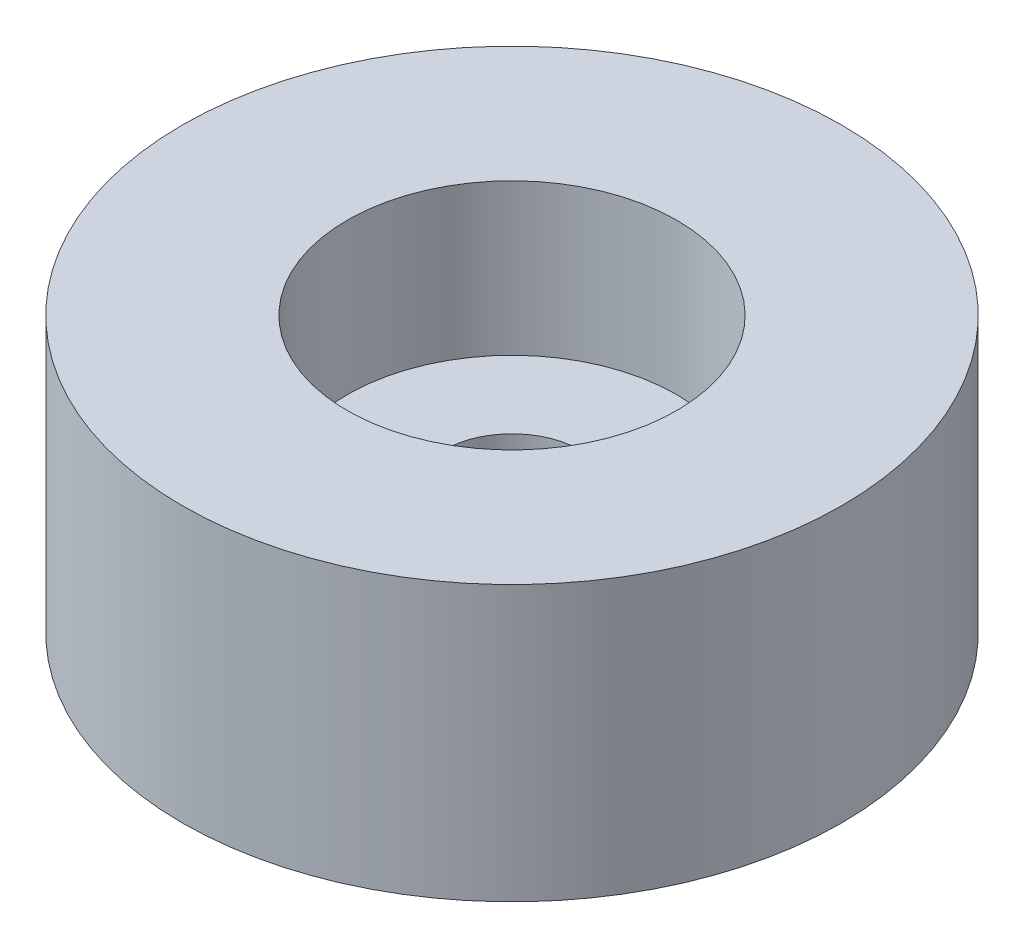
from build123d import *

# Parameters (mm, degrees)
SKETCH1_4_W = 5.55625
SKETCH1_4_H = 2


with BuildPart() as part:
    # Sketch1 → Revolve1 (revolve)
    with BuildSketch(Plane.XY):
        Polygon((3.96875, 5.14375), (3.96875, 0), (19.05, 0), (19.05, 15.875), (9.525, 15.875), (9.525, 7.14375), (9.525, 5.14375), align=None)
    revolve(axis=Axis((0, 0, 0), (0, 1, 0)))


with BuildPart() as body_2:
    # Sketch1_4 → Revolve2 (revolve)
    with BuildSketch(Plane.XY):
        with Locations((6.746875, 6.14375)):
            Rectangle(SKETCH1_4_W, SKETCH1_4_H)
    revolve(axis=Axis((0, 0, 0), (0, 1, 0)))


solid = Compound([part.part, body_2.part])
